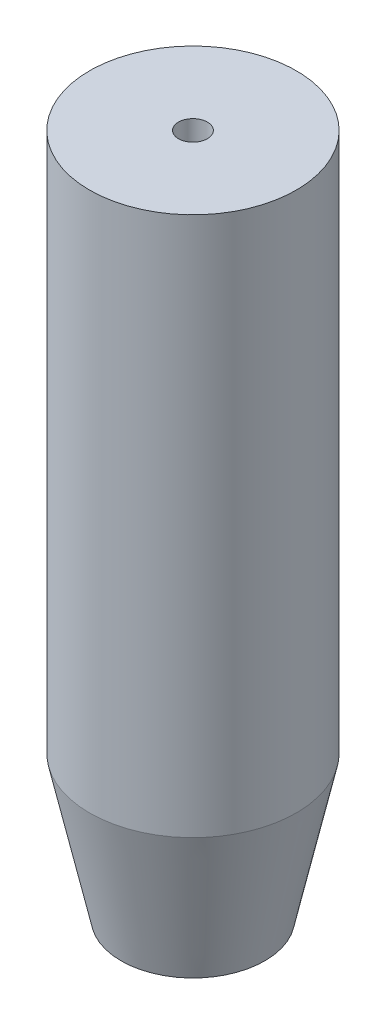
from build123d import *

# Parameters (mm, degrees)
SKETCH1_R                   = 18.25625
BOSS_EXTRUDE1_DEPTH         = 120.65
CHAMFER1_SIZE               = 5.55625
CHAMFER1_SIZE2              = 25.4
F_1_4_20_TAPPED_HOLE1_D     = 5.1054
F_1_4_20_TAPPED_HOLE1_DEPTH = 16.51
F_1_4_20_TAPPED_HOLE1_TIP   = 1.533816902


with BuildPart() as part:
    # Sketch1 → Boss-Extrude1 (new body)
    with BuildSketch(Plane(origin=(0, 0, 0), x_dir=(1, 0, 0), z_dir=(0, 1, 0))):
        Circle(SKETCH1_R)
    extrude(amount=BOSS_EXTRUDE1_DEPTH)

    # Chamfer1
    chamfer1_edges = [part.edges().sort_by_distance(p)[0] for p in [
        (-18.25625, 0, 0),
    ]]
    chamfer1_side = [part.faces().sort_by_distance(p)[0] for p in [
        (0, 0, 0),
    ]]
    chamfer(chamfer1_edges, length=CHAMFER1_SIZE, length2=CHAMFER1_SIZE2, reference=chamfer1_side[0])

    # 1/4-20 Tapped Hole1
    with Locations(Plane(origin=(0, 120.65, 0), x_dir=(1, 0, 0), z_dir=(0, 1, 0))):
        with Locations((0, 0)):
            Hole(F_1_4_20_TAPPED_HOLE1_D / 2, depth=F_1_4_20_TAPPED_HOLE1_DEPTH)
            with Locations((0, 0, -(F_1_4_20_TAPPED_HOLE1_DEPTH + F_1_4_20_TAPPED_HOLE1_TIP / 2))):  # 118° drill point
                Cone(0, F_1_4_20_TAPPED_HOLE1_D / 2, F_1_4_20_TAPPED_HOLE1_TIP, mode=Mode.SUBTRACT)


solid = part.part
